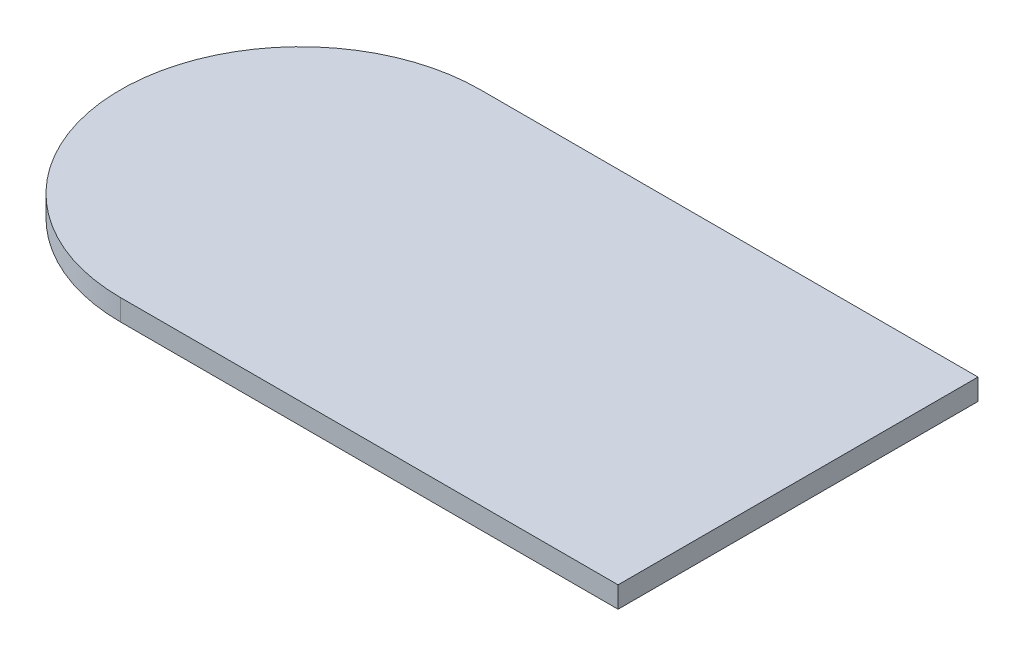
from build123d import *

# Parameters (mm, degrees)
BOSS_EXTRUDE1_DEPTH = 2.54


with BuildPart() as part:
    # Sketch2 → Boss-Extrude1 (new body)
    with BuildSketch(Plane(origin=(0, 0, 0), x_dir=(1, 0, 0), z_dir=(0, 1, 0))):
        with BuildLine():
            Line((0, 21.59), (59.695806552, 21.59))
            Line((59.695806552, 21.59), (59.695806552, -21.59))
            Line((59.695806552, -21.59), (0, -21.59))
            ThreePointArc((0, -21.59), (-21.59, 0), (0, 21.59))
        make_face()
    extrude(amount=BOSS_EXTRUDE1_DEPTH)


solid = part.part
